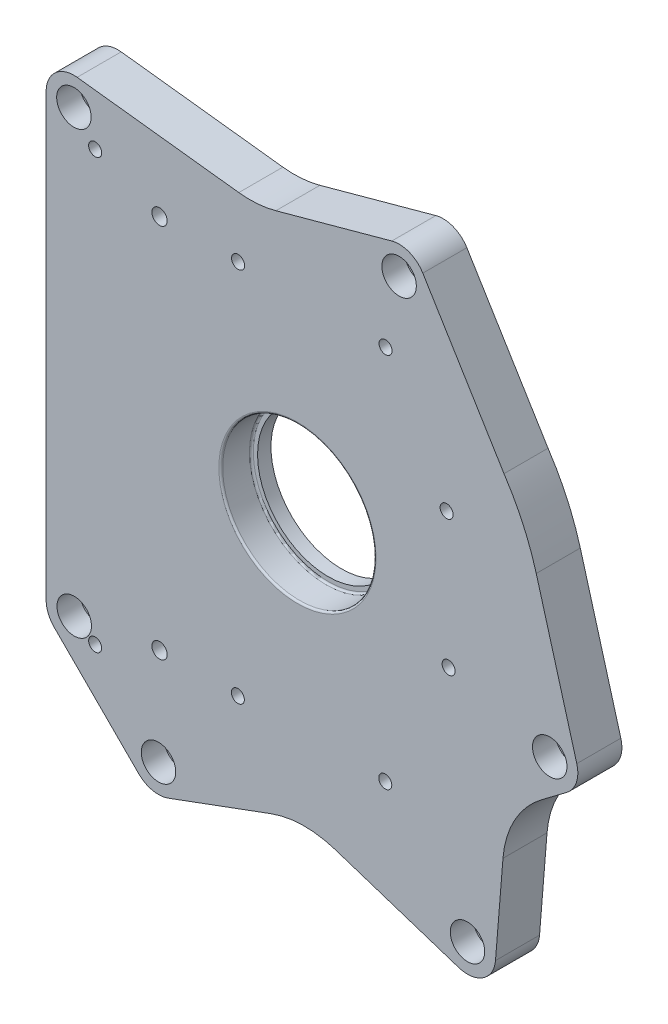
from build123d import *

# Parameters (mm, degrees)
BOSS_EXTRUDE1_DEPTH             = 23
FILLET2_R                       = 50.8
SKETCH2_R                       = 40.05
CUT_EXTRUDE1_DEPTH              = 16
SKETCH5_R                       = 36.83
CUT_EXTRUDE2_DEPTH              = 25.4
FILLET5_R                       = 1
FILLET6_R                       = 1
CBORE_FOR_M10_SHCS7_D           = 10.5
CBORE_FOR_M10_SHCS7_CBORE_D     = 18
CBORE_FOR_M10_SHCS7_CBORE_DEPTH = 12
TAP_DRILL_FOR_M8X1_25_TAP2_D    = 6.8
F_8_0MM_DOWEL_HOLE1_D           = 8
F_8_0MM_DOWEL_HOLE1_DEPTH       = 9
F_8_0MM_DOWEL_HOLE1_TIP         = 2.403442476
F_10_0MM_DOWEL_HOLE3_D          = 10
F_10_0MM_DOWEL_HOLE3_DEPTH      = 10
F_10_0MM_DOWEL_HOLE3_TIP        = 3.004303095
CBORE_FOR_M10_SHCS9_D           = 10.5
CBORE_FOR_M10_SHCS9_CBORE_D     = 18
CBORE_FOR_M10_SHCS9_CBORE_DEPTH = 10


with BuildPart() as part:
    # Sketch1 → Boss-Extrude1 (new body)
    with BuildSketch(Plane.XY):
        with BuildLine():
            Line((84.221105008, -163.490124242), (2.699306526, -136.831626991))
            Line((2.699306526, -136.831626991), (-67.458438584, -162.730244564))
            ThreePointArc((-67.458438584, -162.730244564), (-75.680634631, -163.297391653), (-82.910842941, -159.341351783))
            Line((-82.910842941, -159.341351783), (-126.914053579, -115.336397895))
            ThreePointArc((-126.914053579, -115.336397895), (-130.093640928, -110.577690662), (-131.210211433, -104.964461595))
            Line((-131.210211433, -104.964461595), (-131.213297338, 125.035476514))
            ThreePointArc((-131.213297338, 125.035476514), (-126.350161673, 135.869915187), (-115.02264263, 139.436771249))
            Line((-115.02264263, 139.436771249), (-20.796830867, 128.37488637))
            Line((-20.796830867, 128.37488637), (49.24312976, 147.55277548))
            ThreePointArc((49.24312976, 147.55277548), (58.421803723, 147.044752766), (65.450410839, 141.119820294))
            Line((65.450410839, 141.119820294), (107.841002341, 71.642808501))
            ThreePointArc((107.841002341, 71.642808501), (117.701476238, 53.952608996), (124.683759391, 34.941564155))
            Line((124.683759391, 34.941564155), (145.845410308, -40.455794779))
            ThreePointArc((145.845410308, -40.455794779), (145.61886709, -49.11646402), (140.544799405, -56.138739339))
            Line((140.544799405, -56.138739339), (109.149264581, -79.773969292))
            Line((109.149264581, -79.773969292), (103.401152517, -150.732337669))
            ThreePointArc((103.401152517, -150.732337669), (96.90432541, -161.761540655), (84.221105008, -163.490124242))
        make_face()
    extrude(amount=BOSS_EXTRUDE1_DEPTH)

    # Fillet2
    fillet2_edges = [part.edges().sort_by_distance(p)[0] for p in [
        (109.149264581, -79.773969292, 11.5),
        (2.699306526, -136.831626991, 11.5),
        (-20.796830867, 128.37488637, 11.5),
    ]]
    fillet(fillet2_edges, radius=FILLET2_R)

    # Sketch2 → Cut-Extrude1 (cut)
    with BuildSketch(Plane(origin=(0, 0, 23), x_dir=(-1, 0, 0), z_dir=(0, 0, -1))):
        Circle(SKETCH2_R)
    extrude(amount=CUT_EXTRUDE1_DEPTH, mode=Mode.SUBTRACT)

    # Sketch5 → Cut-Extrude2 (cut)
    with BuildSketch(Plane(origin=(0, 0, 23), x_dir=(-1, 0, 0), z_dir=(0, 0, -1))):
        Circle(SKETCH5_R)
    extrude(amount=CUT_EXTRUDE2_DEPTH, mode=Mode.SUBTRACT)

    # Fillet5
    fillet5_edges = [part.edges().sort_by_distance(p)[0] for p in [
        (40.05, 0, 23),
    ]]
    fillet(fillet5_edges, radius=FILLET5_R)

    # Fillet6
    fillet6_edges = [part.edges().sort_by_distance(p)[0] for p in [
        (40.05, 0, 7),
    ]]
    fillet(fillet6_edges, radius=FILLET6_R)

    # CBORE for M10 SHCS7 (through all)
    with Locations(Plane.XY.offset(23)):
        with Locations((-116.713297339, 125.03567106), (-116.541509562, -104.964264785), (-72.538298924, -148.969218673), (53.072470058, 133.567563544), (131.722431635, -44.419667636), (88.780343848, -149.547952394)):
            CounterBoreHole(CBORE_FOR_M10_SHCS7_D / 2, CBORE_FOR_M10_SHCS7_CBORE_D / 2, CBORE_FOR_M10_SHCS7_CBORE_DEPTH)

    # Tap Drill for M8x1.25 Tap2 (through all)
    with Locations(Plane.XY.offset(23)):
        with Locations((46, 97.92), (-31, 98), (-105.616623552, 111.626092354), (-105.616623552, -112.292869781), (-31.12, -98.35), (45.85, -98.52), (78.925, -30.46), (77.9, 39.75)):
            Hole(TAP_DRILL_FOR_M8X1_25_TAP2_D / 2)

    # Ø8.0mm Dowel Hole1
    with Locations(Plane.XY.offset(23)):
        with Locations((-72, 97.977867106), (-72, -98.122132894)):
            Hole(F_8_0MM_DOWEL_HOLE1_D / 2, depth=F_8_0MM_DOWEL_HOLE1_DEPTH)
            with Locations((0, 0, -(F_8_0MM_DOWEL_HOLE1_DEPTH + F_8_0MM_DOWEL_HOLE1_TIP / 2))):  # 118° drill point
                Cone(0, F_8_0MM_DOWEL_HOLE1_D / 2, F_8_0MM_DOWEL_HOLE1_TIP, mode=Mode.SUBTRACT)

    # Ø10.0mm Dowel Hole3
    with Locations(Plane(origin=(0, 0, 0), x_dir=(-1, 0, 0), z_dir=(0, 0, -1))):
        with Locations((76.55340813, 103.753913834), (-59.102558089, -114.980445858)):
            Hole(F_10_0MM_DOWEL_HOLE3_D / 2, depth=F_10_0MM_DOWEL_HOLE3_DEPTH)
            with Locations((0, 0, -(F_10_0MM_DOWEL_HOLE3_DEPTH + F_10_0MM_DOWEL_HOLE3_TIP / 2))):  # 118° drill point
                Cone(0, F_10_0MM_DOWEL_HOLE3_D / 2, F_10_0MM_DOWEL_HOLE3_TIP, mode=Mode.SUBTRACT)

    # CBORE for M10 SHCS9 (through all)
    with Locations(Plane.XY.offset(23)):
        with Locations((53.072470058, 133.567563544), (131.722431635, -44.419667636), (88.780343848, -149.547952394), (-116.713297339, 125.03567106), (-116.541509562, -104.964264785), (-72.538298924, -148.969218673)):
            CounterBoreHole(CBORE_FOR_M10_SHCS9_D / 2, CBORE_FOR_M10_SHCS9_CBORE_D / 2, CBORE_FOR_M10_SHCS9_CBORE_DEPTH)


solid = part.part
